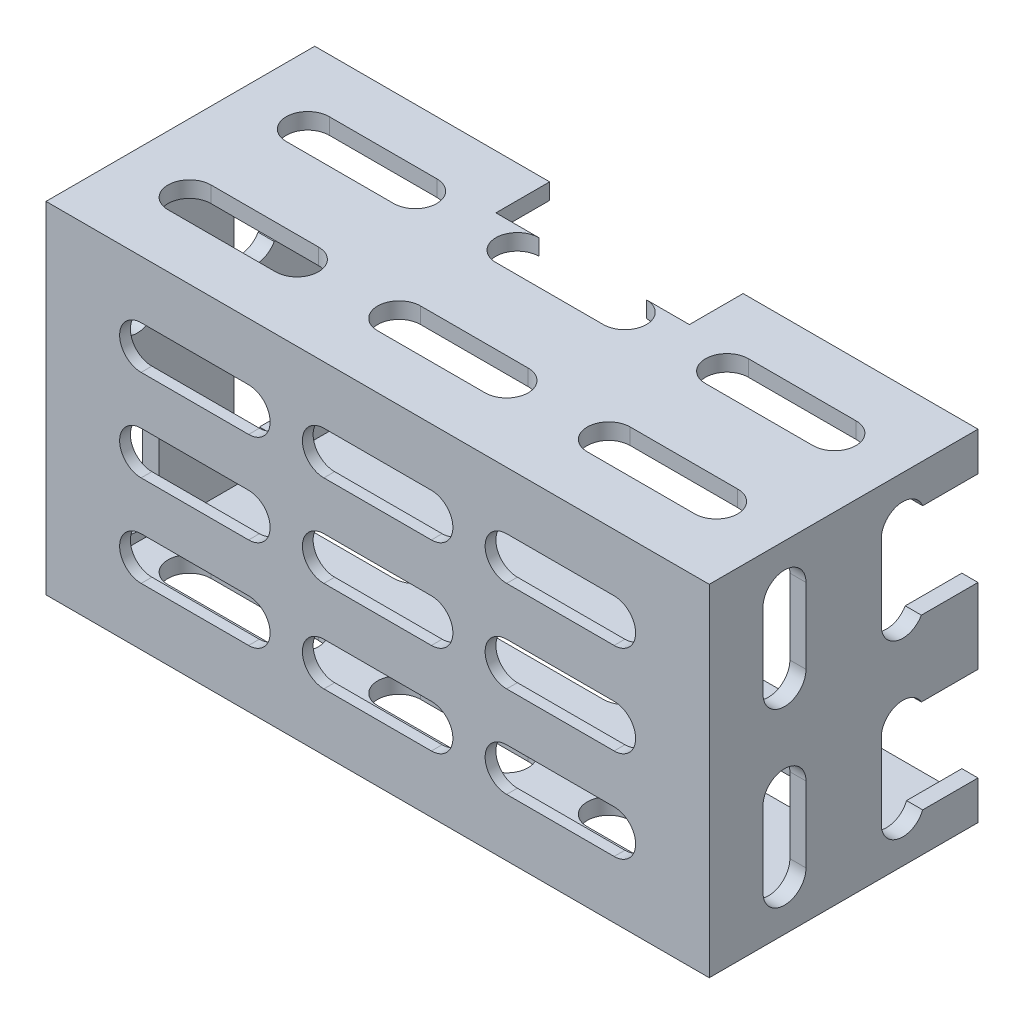
from build123d import *

# Parameters (mm, degrees)
SKETCH1_W           = 61.7
SKETCH1_H           = 31.7
SKETCH1_W_2         = 58.7
SKETCH1_H_2         = 28.7
BOSS_EXTRUDE1_DEPTH = 19
SKETCH2_W           = 61.7
SKETCH2_H           = 31.7
BOSS_EXTRUDE2_DEPTH = 1
BOSS_EXTRUDE3_DEPTH = 5
CUT_EXTRUDE4_DEPTH  = 2
CUT_EXTRUDE2_DEPTH  = 32.7
CUT_EXTRUDE3_DEPTH  = 62.7
SKETCH9_W           = 7
SKETCH9_H           = 8.75
CUT_EXTRUDE5_DEPTH  = 62.7


with BuildPart() as part:
    # Sketch1 → Boss-Extrude1 (new body)
    with BuildSketch(Plane.XY):
        Rectangle(SKETCH1_W, SKETCH1_H)
        Rectangle(SKETCH1_W_2, SKETCH1_H_2, mode=Mode.SUBTRACT)
    extrude(amount=BOSS_EXTRUDE1_DEPTH)

    # Sketch2 → Boss-Extrude2 (add)
    with BuildSketch(Plane.XY.offset(19)):
        Rectangle(SKETCH2_W, SKETCH2_H)
    extrude(amount=BOSS_EXTRUDE2_DEPTH)

    # Sketch3 → Boss-Extrude3 (add)
    with BuildSketch(Plane(origin=(0, 0, 0), x_dir=(-1, 0, 0), z_dir=(0, 0, -1))):
        Polygon((-30.85, -15.85), (30.85, -15.85), (30.85, 15.85), (9, 15.85), (9, 14.35), (29.35, 14.35), (29.35, -14.35), (-29.35, -14.35), (-29.35, 14.35), (-9, 14.35), (-9, 15.85), (-30.85, 15.85), align=None)
    extrude(amount=BOSS_EXTRUDE3_DEPTH)

    # Sketch8 → Cut-Extrude4 (cut, through all)
    with BuildSketch(Plane(origin=(0, 0, 19), x_dir=(-1, 0, 0), z_dir=(0, 0, -1))):
        with BuildLine():
            Line((12, 6.5), (22, 6.5))
            ThreePointArc((22, 6.5), (24, 8.5), (22, 10.5))
            Line((22, 10.5), (12, 10.5))
            ThreePointArc((12, 10.5), (10, 8.5), (12, 6.5))
        make_face()
        with BuildLine():
            Line((12, -2), (22, -2))
            ThreePointArc((22, -2), (24, 0), (22, 2))
            Line((22, 2), (12, 2))
            ThreePointArc((12, 2), (10, 0), (12, -2))
        make_face()
        with BuildLine():
            Line((12, -10.5), (22, -10.5))
            ThreePointArc((22, -10.5), (24, -8.5), (22, -6.5))
            Line((22, -6.5), (12, -6.5))
            ThreePointArc((12, -6.5), (10, -8.5), (12, -10.5))
        make_face()
        with BuildLine():
            Line((-5, -10.5), (5, -10.5))
            ThreePointArc((5, -10.5), (7, -8.5), (5, -6.5))
            Line((5, -6.5), (-5, -6.5))
            ThreePointArc((-5, -6.5), (-7, -8.5), (-5, -10.5))
        make_face()
        with BuildLine():
            Line((-22, -10.5), (-12, -10.5))
            ThreePointArc((-12, -10.5), (-10, -8.5), (-12, -6.5))
            Line((-12, -6.5), (-22, -6.5))
            ThreePointArc((-22, -6.5), (-24, -8.5), (-22, -10.5))
        make_face()
        with BuildLine():
            Line((-22, -2), (-12, -2))
            ThreePointArc((-12, -2), (-10, 0), (-12, 2))
            Line((-12, 2), (-22, 2))
            ThreePointArc((-22, 2), (-24, 0), (-22, -2))
        make_face()
        with BuildLine():
            Line((-5, 6.5), (5, 6.5))
            ThreePointArc((5, 6.5), (7, 8.5), (5, 10.5))
            Line((5, 10.5), (-5, 10.5))
            ThreePointArc((-5, 10.5), (-7, 8.5), (-5, 6.5))
        make_face()
        with BuildLine():
            Line((-22, 6.5), (-12, 6.5))
            ThreePointArc((-12, 6.5), (-10, 8.5), (-12, 10.5))
            Line((-12, 10.5), (-22, 10.5))
            ThreePointArc((-22, 10.5), (-24, 8.5), (-22, 6.5))
        make_face()
        with BuildLine():
            Line((-5, -2), (5, -2))
            ThreePointArc((5, -2), (7, 0), (5, 2))
            Line((5, 2), (-5, 2))
            ThreePointArc((-5, 2), (-7, 0), (-5, -2))
        make_face()
    extrude(amount=-CUT_EXTRUDE4_DEPTH, mode=Mode.SUBTRACT)

    # Sketch5 → Cut-Extrude2 (cut, through all)
    with BuildSketch(Plane(origin=(-15, 15.85, 0), x_dir=(1, 0, 0), z_dir=(0, -1, 0))):
        with BuildLine():
            Line((-9.5, 4), (0.5, 4))
            ThreePointArc((0.5, 4), (2.5, 2), (0.5, 0))
            Line((0.5, 0), (-9.5, 0))
            ThreePointArc((-9.5, 0), (-11.5, 2), (-9.5, 4))
        make_face()
        with BuildLine():
            Line((10, 0), (20, 0))
            ThreePointArc((20, 0), (22, 2), (20, 4))
            Line((20, 4), (10, 4))
            ThreePointArc((10, 4), (8, 2), (10, 0))
        make_face()
        with BuildLine():
            Line((29.5, 0), (39.5, 0))
            ThreePointArc((39.5, 0), (41.5, 2), (39.5, 4))
            Line((39.5, 4), (29.5, 4))
            ThreePointArc((29.5, 4), (27.5, 2), (29.5, 0))
        make_face()
        with BuildLine():
            Line((10, 11), (20, 11))
            ThreePointArc((20, 11), (22, 13), (20, 15))
            Line((20, 15), (10, 15))
            ThreePointArc((10, 15), (8, 13), (10, 11))
        make_face()
        with BuildLine():
            Line((29.5, 11), (39.5, 11))
            ThreePointArc((39.5, 11), (41.5, 13), (39.5, 15))
            Line((39.5, 15), (29.5, 15))
            ThreePointArc((29.5, 15), (27.5, 13), (29.5, 11))
        make_face()
        with BuildLine():
            Line((-9.5, 11), (0.5, 11))
            ThreePointArc((0.5, 11), (2.5, 13), (0.5, 15))
            Line((0.5, 15), (-9.5, 15))
            ThreePointArc((-9.5, 15), (-11.5, 13), (-9.5, 11))
        make_face()
    extrude(amount=CUT_EXTRUDE2_DEPTH, mode=Mode.SUBTRACT)

    # Sketch7 → Cut-Extrude3 (cut, through all)
    with BuildSketch(Plane(origin=(30.85, -15, 0), x_dir=(0, 0, -1), z_dir=(-1, 0, 0))):
        with BuildLine():
            Line((-15, -26.5), (-15, -19.5))
            ThreePointArc((-15, -19.5), (-13, -17.5), (-11, -19.5))
            Line((-11, -19.5), (-11, -26.5))
            ThreePointArc((-11, -26.5), (-13, -28.5), (-15, -26.5))
        make_face()
        with BuildLine():
            Line((0, -26.5), (0, -19.5))
            ThreePointArc((0, -19.5), (-2, -17.5), (-4, -19.5))
            Line((-4, -19.5), (-4, -26.5))
            ThreePointArc((-4, -26.5), (-2, -28.5), (0, -26.5))
        make_face()
        with BuildLine():
            Line((0, -10.5), (0, -3.5))
            ThreePointArc((0, -3.5), (-2, -1.5), (-4, -3.5))
            Line((-4, -3.5), (-4, -10.5))
            ThreePointArc((-4, -10.5), (-2, -12.5), (0, -10.5))
        make_face()
        with BuildLine():
            Line((-11, -10.5), (-11, -3.5))
            ThreePointArc((-11, -3.5), (-13, -1.5), (-15, -3.5))
            Line((-15, -3.5), (-15, -10.5))
            ThreePointArc((-15, -10.5), (-13, -12.5), (-11, -10.5))
        make_face()
    extrude(amount=CUT_EXTRUDE3_DEPTH, mode=Mode.SUBTRACT)

    # Sketch9 → Cut-Extrude5 (cut, through all)
    with BuildSketch(Plane.ZY.offset(30.85)):
        with Locations((-1.5, 7.875)):
            Rectangle(SKETCH9_W, SKETCH9_H)
        with Locations((-1.5, -7.875)):
            Rectangle(SKETCH9_W, SKETCH9_H)
    extrude(amount=-CUT_EXTRUDE5_DEPTH, mode=Mode.SUBTRACT)


solid = part.part
